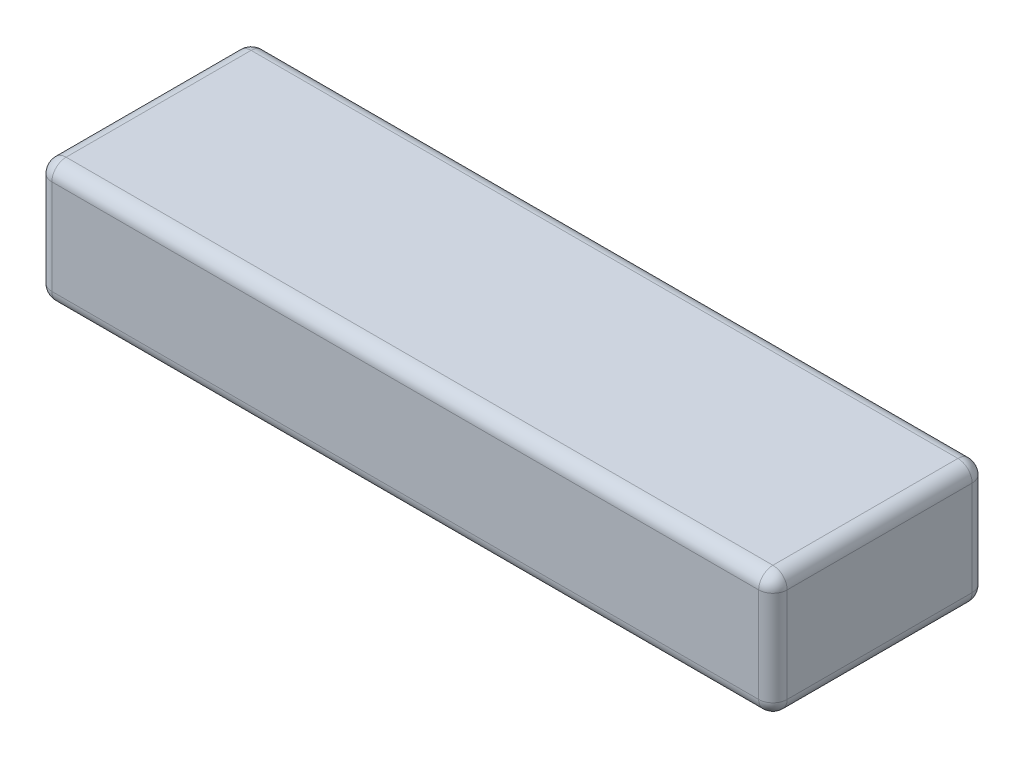
from build123d import *

# Parameters (mm, degrees)
ESQUISSE1_W        = 155
ESQUISSE1_H        = 45
BOSS_EXTRU_1_DEPTH = 26
CONG_1_R           = 3


with BuildPart() as part:
    # Esquisse1 → Boss.-Extru.1 (new body)
    with BuildSketch(Plane(origin=(0, 0, 0), x_dir=(1, 0, 0), z_dir=(0, 1, 0))):
        with Locations((-77.5, 0)):
            Rectangle(ESQUISSE1_W, ESQUISSE1_H)
    extrude(amount=BOSS_EXTRU_1_DEPTH)

    # Congé1
    cong_1_edges = [part.edges().sort_by_distance(p)[0] for p in [
        (0, 26, 0),
        (-77.5, 26, -22.5),
        (-155, 26, 0),
        (-77.5, 0, -22.5),
        (0, 0, 0),
        (-77.5, 0, 22.5),
        (-155, 0, 0),
        (-77.5, 26, 22.5),
        (-155, 13, -22.5),
        (0, 13, -22.5),
        (0, 13, 22.5),
        (-155, 13, 22.5),
    ]]
    fillet(cong_1_edges, radius=CONG_1_R)


solid = part.part
